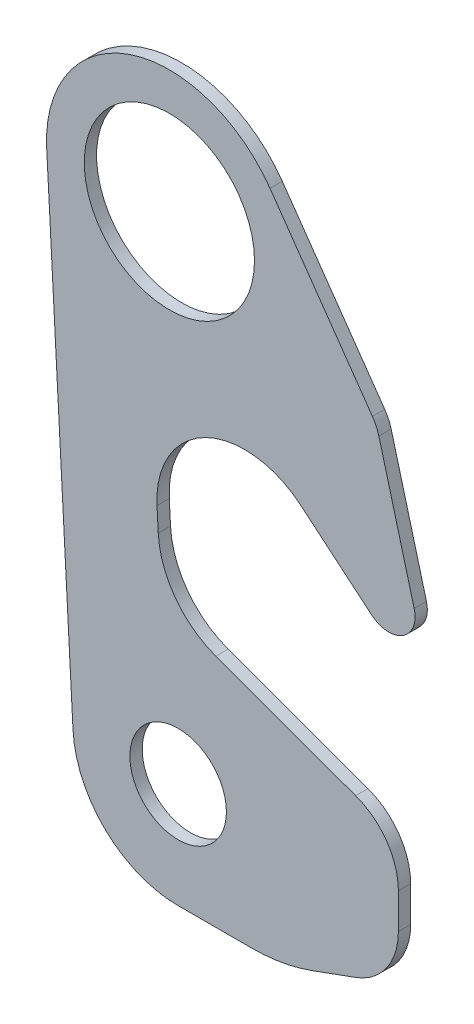
from build123d import *

# Parameters (mm, degrees)
SKETCH1_R          = 48.5
SKETCH1_R_2        = 27.5
BASE_EXTRUDE_DEPTH = 7


with BuildPart() as part:
    # Sketch1 → Base-Extrude (new body)
    with BuildSketch(Plane.XY):
        with BuildLine():
            Line((-6.343577624, -161.833816921), (-7.052214122, -148.618592863))
            ThreePointArc((-7.052214122, -148.618592863), (20.539062499, -101.208107275), (75.015436064, -107.639080177))
            Line((75.015436064, -107.639080177), (115.358185855, -141.490666647))
            ThreePointArc((115.358185855, -141.490666647), (133.059494125, -142.650871687), (139.488887394, -126.117714323))
            Line((139.488887394, -126.117714323), (119.384026274, -51.085351142))
            ThreePointArc((119.384026274, -51.085351142), (117.893575292, -46.990370726), (115.714681724, -43.216416361))
            Line((115.714681724, -43.216416361), (57.3406431, 40.150350545))
            ThreePointArc((57.3406431, 40.150350545), (-22.829860749, 66.172482636), (-69.899577583, -3.748206743))
            Line((-69.899577583, -3.748206743), (-54.913923642, -283.212748636))
            ThreePointArc((-54.913923642, -283.212748636), (-36.27490207, -323.547473625), (5, -340))
            Line((5, -340), (46.927843862, -340))
            ThreePointArc((46.927843862, -340), (64.292661629, -338.480775301), (81.129858195, -333.969262079))
            Line((81.129858195, -333.969262079), (106.154745303, -324.860948055))
            ThreePointArc((106.154745303, -324.860948055), (123.808625639, -311.314649231), (130.5, -290.092321086))
            Line((130.5, -290.092321086), (130.5, -269.907678914))
            ThreePointArc((130.5, -269.907678914), (123.808625639, -248.685350769), (106.154745303, -235.139051945))
            Line((106.154745303, -235.139051945), (26.483684912, -206.14115743))
            ThreePointArc((26.483684912, -206.14115743), (3.409872911, -188.922008159), (-6.343577624, -161.833816921))
        make_face()
        Circle(SKETCH1_R, mode=Mode.SUBTRACT)
        with Locations((5, -280)):
            Circle(SKETCH1_R_2, mode=Mode.SUBTRACT)
    extrude(amount=BASE_EXTRUDE_DEPTH)


solid = part.part
